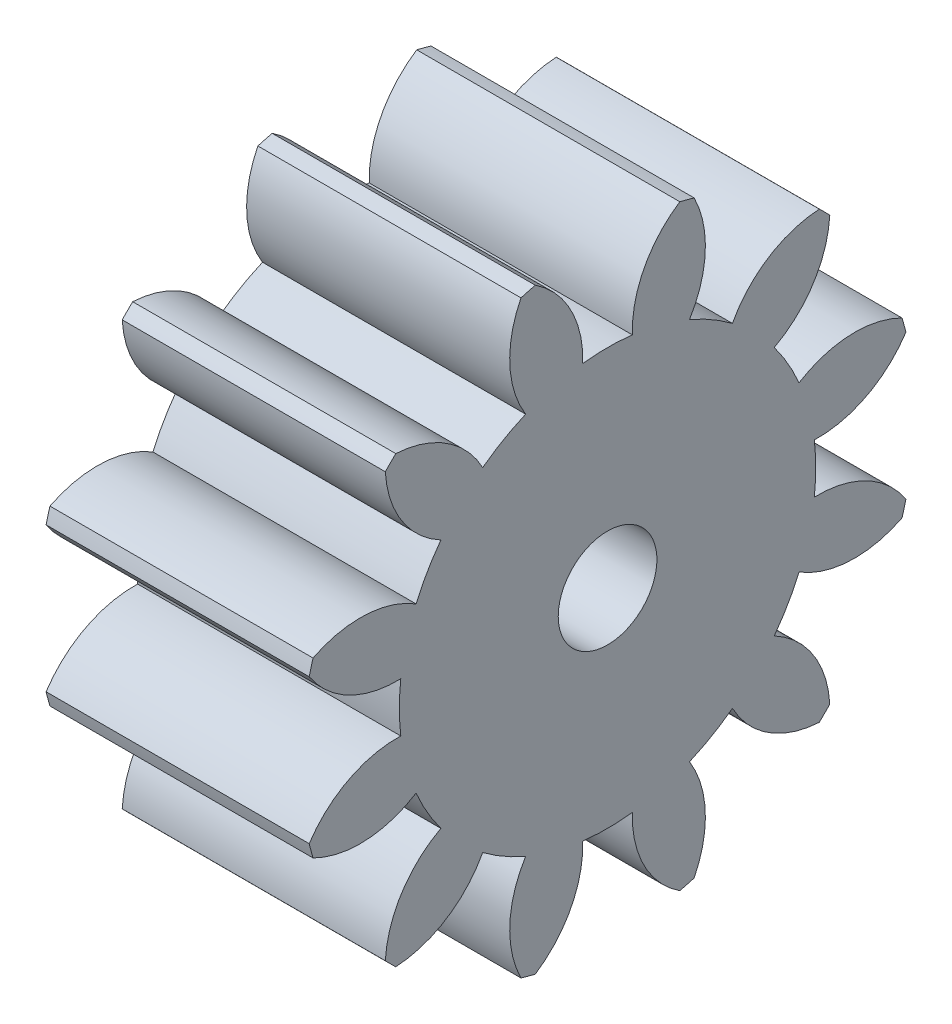
from build123d import *

# Parameters (mm, degrees)
BASPROSKE_W     = 12.7
BASPROSKE_H     = 14.816666667
TOOTHCUT_DEPTH  = 25.502188111
TEETHCUTS_COUNT = 12
TEETHCUTS_ANGLE = 330
BORSKE_R        = 2.38125
BORE_DEPTH      = 50.8000508


with BuildPart() as part:
    # BasProSke → Base-Revolve (revolve)
    with BuildSketch(Plane(origin=(0, 0, 0), x_dir=(1, 0, 0), z_dir=(0, 1, 0)), mode=Mode.PRIVATE) as base_revolve_sk:
        with Locations((6.35, 7.408333334)):
            Rectangle(BASPROSKE_W, BASPROSKE_H)
    revolve(base_revolve_sk.sketch.rotate(Axis((-10, 0, 0), (1, 0, 0)), 180), axis=Axis((-10, 0, 0), (1, 0, 0)))

    # TooCutSke → ToothCut (cut, through all)
    with BuildSketch(Plane(origin=(0, 0, 0), x_dir=(0, 0, -1), z_dir=(1, 0, 0))):
        with BuildLine():
            ThreePointArc((1.196778833, 9.981405303), (0, 10.052896667), (-1.196778833, 9.981405303))
            ThreePointArc((-1.196778833, 9.981405303), (-1.772394731, 12.506169172), (-3.517726707, 14.419172714))
            ThreePointArc((-3.517726707, 14.419172714), (0, 14.842066667), (3.517726707, 14.419172714))
            ThreePointArc((3.517726707, 14.419172714), (1.772394731, 12.506169172), (1.196778833, 9.981405303))
        make_face()
    toothcut = extrude(amount=TOOTHCUT_DEPTH, mode=Mode.SUBTRACT)

    # TeethCuts: ToothCut ×12 about axis
    teethcuts_axis = Axis((-10, 0, 0), (1, 0, 0))
    for i in range(1, TEETHCUTS_COUNT):
        add(toothcut.rotate(teethcuts_axis, i * TEETHCUTS_ANGLE / (TEETHCUTS_COUNT - 1)), mode=Mode.SUBTRACT)

    # BorSke → Bore (cut, symmetric)
    with BuildSketch(Plane(origin=(0, 0, 0), x_dir=(0, 0, -1), z_dir=(1, 0, 0))):
        with Locations(Location((0, 0, 0), (0, 0, 180))):
            Circle(BORSKE_R)
    extrude(amount=BORE_DEPTH, both=True, mode=Mode.SUBTRACT)


solid = part.part
